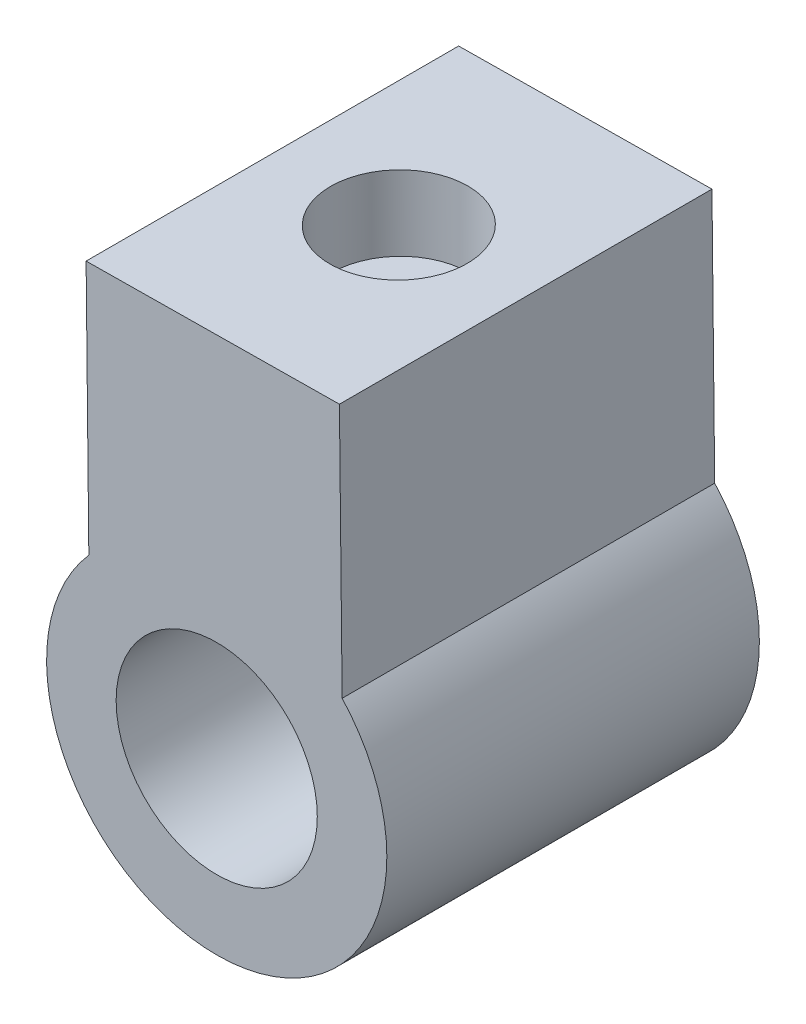
from build123d import *

# Parameters (mm, degrees)
BOSS_EXTRUDE1_DEPTH = 15
SKETCH2_R           = 2.75
CUT_EXTRUDE1_DEPTH  = 3
SKETCH3_R           = 1.35
CUT_EXTRUDE2_DEPTH  = 9
SKETCH4_R           = 4.05
CUT_EXTRUDE3_DEPTH  = 16


with BuildPart() as part:
    # Sketch1 → Boss-Extrude1 (new body)
    with BuildSketch(Plane.XY):
        with BuildLine():
            Line((0.700840098, 16.455896919), (0.810681557, 6.255896919))
            ThreePointArc((0.810681557, 6.255896919), (5.886159138, 8.587996721), (11.010681557, 6.365738378))
            Line((11.010681557, 6.365738378), (10.900840098, 16.565738378))
            Line((10.900840098, 16.565738378), (0.700840098, 16.455896919))
        make_face()
        with BuildLine():
            ThreePointArc((11.010681557, 6.365738378), (5.886159138, 8.587996721), (0.810681557, 6.255896919))
            Line((0.810681557, 6.255896919), (11.010681557, 6.365738378))
        make_face()
        with BuildLine():
            Line((11.010681557, 6.365738378), (0.810681557, 6.255896919))
            ThreePointArc((0.810681557, 6.255896919), (3.546395485, -4.672331118), (12.809920939, 1.738393871))
            ThreePointArc((12.809920939, 1.738393871), (12.344285051, 4.220811017), (11.010681557, 6.365738378))
        make_face()
    extrude(amount=BOSS_EXTRUDE1_DEPTH)

    # Sketch2 → Cut-Extrude1 (cut)
    with BuildSketch(Plane(origin=(-0.177107964, 16.446442498, 0), x_dir=(0.999942022, 0.010768146, 0), z_dir=(-0.010768146, 0.999942022, 0))):
        with Locations((5.96903182, -7.499323697)):
            Circle(SKETCH2_R)
    extrude(amount=-CUT_EXTRUDE1_DEPTH, mode=Mode.SUBTRACT)

    # Sketch3 → Cut-Extrude2 (cut)
    with BuildSketch(Plane(origin=(-0.144803526, 13.446616432, 0), x_dir=(0.999942022, 0.010768146, 0), z_dir=(-0.010768146, 0.999942022, 0))):
        with Locations((5.96903182, -7.499323697)):
            Circle(SKETCH3_R)
    extrude(amount=-CUT_EXTRUDE2_DEPTH, mode=Mode.SUBTRACT)

    # Sketch4 → Cut-Extrude3 (cut, through all)
    with BuildSketch(Plane(origin=(0, 0, 0), x_dir=(-1, 0, 0), z_dir=(0, 0, -1))):
        with Locations((-5.959920939, 1.738393871)):
            Circle(SKETCH4_R)
    extrude(amount=-CUT_EXTRUDE3_DEPTH, mode=Mode.SUBTRACT)


solid = part.part
